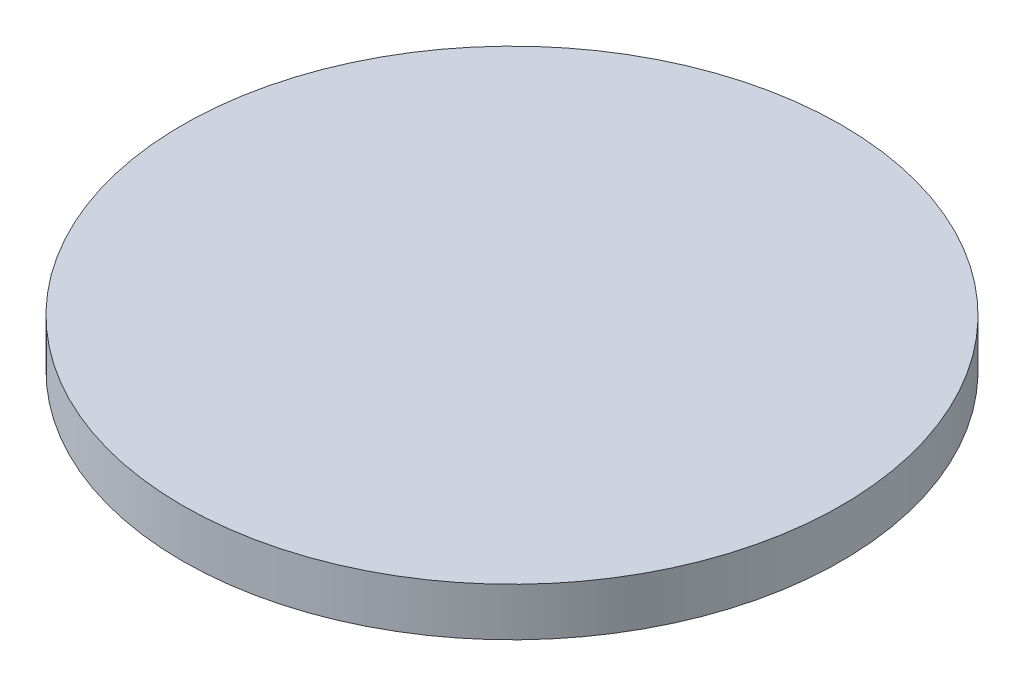
from build123d import *

# Parameters (mm, degrees)
SKETCH1_R           = 21.75
BOSS_EXTRUDE1_DEPTH = 3.175
SKETCH1_3_R         = 0.5
CUT_EXTRUDE1_DEPTH  = 1


with BuildPart() as part:
    # Sketch1 → Boss-Extrude1 (new body)
    with BuildSketch(Plane(origin=(0, 0, 0), x_dir=(1, 0, 0), z_dir=(0, 1, 0))):
        Circle(SKETCH1_R)
    extrude(amount=BOSS_EXTRUDE1_DEPTH)

    # Sketch1_3 → Cut-Extrude1 (cut)
    with BuildSketch(Plane(origin=(0, 0, 0), x_dir=(1, 0, 0), z_dir=(0, 1, 0))):
        Circle(SKETCH1_3_R)
    extrude(amount=CUT_EXTRUDE1_DEPTH, mode=Mode.SUBTRACT)


solid = part.part
